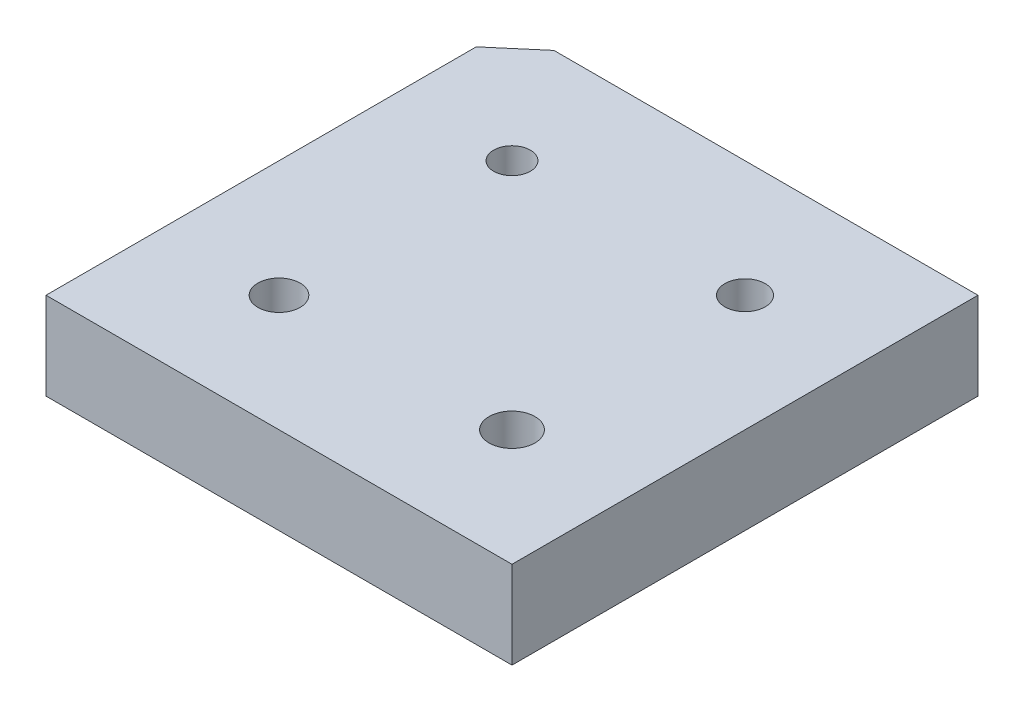
from build123d import *

# Parameters (mm, degrees)
SKETCH1_W           = 50.8
SKETCH1_H           = 50.8
BOSS_EXTRUDE1_DEPTH = 4.7625
SKETCH2_W           = 50.8
SKETCH2_H           = 50.8
SKETCH2_W_2         = 25.4
SKETCH2_H_2         = 25.4
SKETCH2_R           = 1.00076
SKETCH2_R_2         = 1.09982
SKETCH2_R_3         = 1.15062
SKETCH2_R_4         = 1.24968
CUT_EXTRUDE1_DEPTH  = 5.7625
CUT_EXTRUDE2_DEPTH  = 5.7625


with BuildPart() as part:
    # Sketch1 → Boss-Extrude1 (new body)
    with BuildSketch(Plane(origin=(0, 0, 0), x_dir=(1, 0, 0), z_dir=(0, 1, 0))):
        Rectangle(SKETCH1_W, SKETCH1_H)
    extrude(amount=BOSS_EXTRUDE1_DEPTH)

    # Sketch2 → Cut-Extrude1 (cut, through all)
    with BuildSketch(Plane(origin=(0, 4.7625, 0), x_dir=(1, 0, 0), z_dir=(0, 1, 0))):
        Rectangle(SKETCH2_W, SKETCH2_H)
        Rectangle(SKETCH2_W_2, SKETCH2_H_2, mode=Mode.SUBTRACT)
        with Locations((-6.35, 6.35)):
            Circle(SKETCH2_R)
        with Locations((6.35, 6.35)):
            Circle(SKETCH2_R_2)
        with Locations((-6.35, -6.35)):
            Circle(SKETCH2_R_3)
        with Locations((6.35, -6.35)):
            Circle(SKETCH2_R_4)
    extrude(amount=-CUT_EXTRUDE1_DEPTH, mode=Mode.SUBTRACT)

    # Sketch3 → Cut-Extrude2 (cut, through all)
    with BuildSketch(Plane(origin=(0, 4.7625, 0), x_dir=(1, 0, 0), z_dir=(0, 1, 0))):
        Polygon((-10.414075549, 12.7), (-12.7, 12.7), (-12.7, 10.750584792), align=None)
    extrude(amount=-CUT_EXTRUDE2_DEPTH, mode=Mode.SUBTRACT)


solid = part.part
